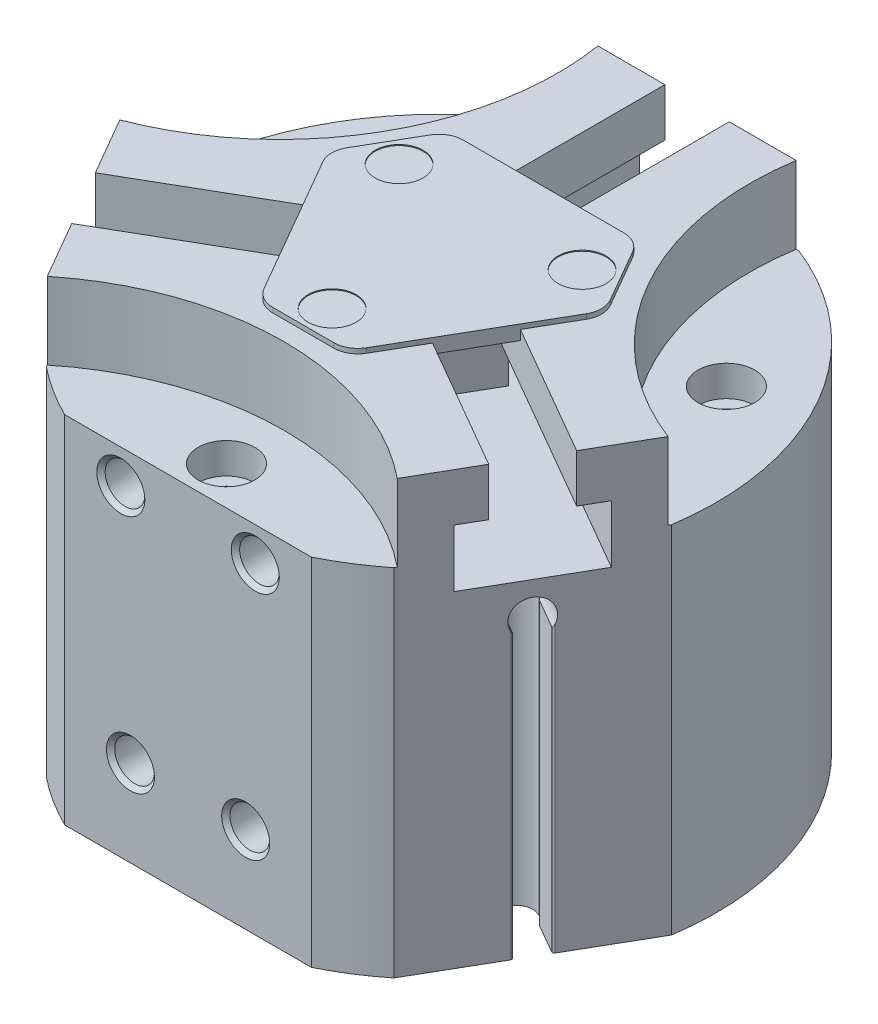
from build123d import *

# Parameters (mm, degrees)
BOSS_EXTRUDE1_DEPTH = 45
SKETCH2_W           = 68
SKETCH2_H           = 68
CUT_EXTRUDE1_DEPTH  = 8
CUT_EXTRUDE2_DEPTH  = 30.5
CUT_EXTRUDE3_DEPTH  = 30.5
CUT_EXTRUDE4_DEPTH  = 30.5
HOLE1_D             = 3
HOLE1_DEPTH         = 5
HOLE2_D             = 3
HOLE2_DEPTH         = 5
HOLE3_D             = 2.459
HOLE3_DEPTH         = 9
HOLE3_CSINK_D       = 3
HOLE3_CSINK_ANGLE   = 90
HOLE3_TIP           = 0.709852156
HOLE4_D             = 2.459
HOLE4_DEPTH         = 9
HOLE4_CSINK_D       = 3
HOLE4_CSINK_ANGLE   = 90
HOLE4_TIP           = 0.709852156
HOLE5_D             = 25
HOLE5_DEPTH         = 2
CUT_EXTRUDE5_DEPTH  = 16
CUT_EXTRUDE6_DEPTH  = 24.3
CUT_EXTRUDE7_DEPTH  = 16
CUT_EXTRUDE8_DEPTH  = 24.3
CUT_EXTRUDE9_DEPTH  = 16
CUT_EXTRUDE10_DEPTH = 24.3
BOSS_EXTRUDE2_DEPTH = 0.5
SKETCH33_R          = 2.5
CUT_EXTRUDE11_DEPTH = 0.1
SKETCH34_R          = 2.5
CUT_EXTRUDE12_DEPTH = 0.1
SKETCH35_R          = 2.5
CUT_EXTRUDE13_DEPTH = 0.1


with BuildPart() as part:
    # Sketch1 → Boss-Extrude1 (new body)
    with BuildSketch(Plane(origin=(0, 0, 0), x_dir=(1, 0, 0), z_dir=(0, 1, 0))):
        with BuildLine():
            Line((-28.674188524, -4.33484861), (-18.09118328, -22.66515139))
            ThreePointArc((-18.09118328, -22.66515139), (-15.55781991, -24.473541624), (-12.845232579, -26))
            Line((-12.845232579, -26), (12.845232579, -26))
            ThreePointArc((12.845232579, -26), (15.55781991, -24.473541624), (18.09118328, -22.66515139))
            Line((18.09118328, -22.66515139), (28.674188524, -4.33484861))
            ThreePointArc((28.674188524, -4.33484861), (25.11473671, 14.5), (10.583005244, 27))
            Line((10.583005244, 27), (-10.583005244, 27))
            ThreePointArc((-10.583005244, 27), (-25.11473671, 14.5), (-28.674188524, -4.33484861))
        make_face()
    extrude(amount=BOSS_EXTRUDE1_DEPTH)

    # Sketch2 → Cut-Extrude1 (cut)
    with BuildSketch(Plane(origin=(0, 45, 0), x_dir=(1, 0, 0), z_dir=(0, 1, 0))):
        Rectangle(SKETCH2_W, SKETCH2_H)
        with BuildLine():
            Line((-30, -30), (-24.819347292, -30))
            ThreePointArc((-24.819347292, -30), (0, -16), (24.819347292, -30))
            Line((24.819347292, -30), (30, -30))
            Line((30, -30), (30, -5.077501522))
            ThreePointArc((30, -5.077501522), (13.484446732, 8.664238198), (10.957753515, 30))
            Line((10.957753515, 30), (-10.957753515, 30))
            ThreePointArc((-10.957753515, 30), (-13.484446732, 8.664238198), (-30, -5.077501522))
            Line((-30, -5.077501522), (-30, -30))
        make_face(mode=Mode.SUBTRACT)
    extrude(amount=-CUT_EXTRUDE1_DEPTH, mode=Mode.SUBTRACT)

    # Sketch3 → Cut-Revolve1 (revolve, cut)
    with BuildSketch(Plane(origin=(0, 0, 0), x_dir=(0, 0, -1), z_dir=(1, 0, 0))):
        Polygon((-22, 37), (-19.05, 37), (-19.05, 33.8), (-20.35, 33.8), (-20.35, 8), (-20.379, 8), (-20.379, 0.379), (-20, 0), (-22, 0), align=None)
    revolve(axis=Axis((0, 0, 22), (0, 1, 0)), mode=Mode.SUBTRACT)

    # Sketch4 → Cut-Revolve2 (revolve, cut)
    with BuildSketch(Plane(origin=(19.05, 0, 0), x_dir=(0, 0, -1), z_dir=(1, 0, 0))):
        Polygon((11, 37), (13.95, 37), (13.95, 33.8), (12.65, 33.8), (12.65, 8), (12.621, 8), (12.621, 0.379), (13, 0), (11, 0), align=None)
    revolve(axis=Axis((19.05, 0, -11), (0, 1, 0)), mode=Mode.SUBTRACT)

    # Sketch5 → Cut-Revolve3 (revolve, cut)
    with BuildSketch(Plane(origin=(-19.05, 0, 0), x_dir=(0, 0, -1), z_dir=(1, 0, 0))):
        Polygon((11, 37), (13.95, 37), (13.95, 33.8), (12.65, 33.8), (12.65, 8), (12.621, 8), (12.621, 0.379), (13, 0), (11, 0), align=None)
    revolve(axis=Axis((-19.05, 0, -11), (0, 1, 0)), mode=Mode.SUBTRACT)

    # Sketch6 → Cut-Extrude2 (cut)
    with BuildSketch(Plane(origin=(0, 0, 0), x_dir=(1, 0, 0), z_dir=(0, 1, 0))):
        with BuildLine():
            Line((-1.9, 28), (-1.9, 27))
            Line((-1.9, 27), (-1.7, 27))
            ThreePointArc((-1.7, 27), (-1.558578644, 26.941421356), (-1.5, 26.8))
            Line((-1.5, 26.8), (-1.5, 23.3))
            ThreePointArc((-1.5, 23.3), (-1.551920858, 23.16556575), (-1.680725676, 23.100930915))
            Line((-1.680725676, 23.100930915), (-1.699955038, 23.099069085))
            ThreePointArc((-1.699955038, 23.099069085), (-1.834790164, 23.027476578), (-1.879833426, 22.881609849))
            Line((-1.879833426, 22.881609849), (-1.7923744, 21.93448864))
            ThreePointArc((-1.7923744, 21.93448864), (0, 20.3), (1.7923744, 21.93448864))
            Line((1.7923744, 21.93448864), (1.879833426, 22.881609849))
            ThreePointArc((1.879833426, 22.881609849), (1.834790164, 23.027476578), (1.699955038, 23.099069085))
            Line((1.699955038, 23.099069085), (1.680725676, 23.100930915))
            ThreePointArc((1.680725676, 23.100930915), (1.551920858, 23.16556575), (1.5, 23.3))
            Line((1.5, 23.3), (1.5, 26.8))
            ThreePointArc((1.5, 26.8), (1.558578644, 26.941421356), (1.7, 27))
            Line((1.7, 27), (1.9, 27))
            Line((1.9, 27), (1.9, 28))
            Line((1.9, 28), (-1.9, 28))
        make_face()
    extrude(amount=CUT_EXTRUDE2_DEPTH, mode=Mode.SUBTRACT)

    # Sketch7 → Cut-Extrude3 (cut)
    with BuildSketch(Plane(origin=(0, 0, 0), x_dir=(1, 0, 0), z_dir=(0, 1, 0))):
        with BuildLine():
            Line((-25.198711306, -12.354551733), (-23.298711306, -15.645448267))
            Line((-23.298711306, -15.645448267), (-22.432685902, -15.145448267))
            Line((-22.432685902, -15.145448267), (-22.532685902, -14.972243186))
            ThreePointArc((-22.532685902, -14.972243186), (-22.552665987, -14.820479377), (-22.459480821, -14.699038106))
            Line((-22.459480821, -14.699038106), (-19.428391908, -12.949038106))
            ThreePointArc((-19.428391908, -12.949038106), (-19.286008003, -12.926785762), (-19.165630186, -13.00601659))
            Line((-19.165630186, -13.00601659), (-19.154403112, -13.021738791))
            ThreePointArc((-19.154403112, -13.021738791), (-19.024984619, -13.102713181), (-18.876138696, -13.068788426))
            Line((-18.876138696, -13.068788426), (-18.099637181, -12.519486083))
            ThreePointArc((-18.099637181, -12.519486083), (-17.580315697, -10.15), (-19.892011581, -9.415002557))
            Line((-19.892011581, -9.415002557), (-20.755972122, -9.812821423))
            ThreePointArc((-20.755972122, -9.812821423), (-20.859774783, -9.924763397), (-20.85435815, -10.077330294))
            Line((-20.85435815, -10.077330294), (-20.846355862, -10.094914325))
            ThreePointArc((-20.846355862, -10.094914325), (-20.837928861, -10.238779987), (-20.928391908, -10.350961894))
            Line((-20.928391908, -10.350961894), (-23.959480821, -12.100961894))
            ThreePointArc((-23.959480821, -12.100961894), (-24.11124463, -12.120941979), (-24.232685902, -12.027756814))
            Line((-24.232685902, -12.027756814), (-24.332685902, -11.854551733))
            Line((-24.332685902, -11.854551733), (-25.198711306, -12.354551733))
        make_face()
    extrude(amount=CUT_EXTRUDE3_DEPTH, mode=Mode.SUBTRACT)

    # Sketch8 → Cut-Extrude4 (cut)
    with BuildSketch(Plane(origin=(0, 0, 0), x_dir=(1, 0, 0), z_dir=(0, 1, 0))):
        with BuildLine():
            Line((18.099637181, -12.519486083), (18.876138696, -13.068788426))
            ThreePointArc((18.876138696, -13.068788426), (19.024984619, -13.102713181), (19.154403112, -13.021738791))
            Line((19.154403112, -13.021738791), (19.165630186, -13.00601659))
            ThreePointArc((19.165630186, -13.00601659), (19.286008003, -12.926785762), (19.428391908, -12.949038106))
            Line((19.428391908, -12.949038106), (22.459480821, -14.699038106))
            ThreePointArc((22.459480821, -14.699038106), (22.552665987, -14.820479377), (22.532685902, -14.972243186))
            Line((22.532685902, -14.972243186), (22.432685902, -15.145448267))
            Line((22.432685902, -15.145448267), (23.298711306, -15.645448267))
            Line((23.298711306, -15.645448267), (25.198711306, -12.354551733))
            Line((25.198711306, -12.354551733), (24.332685902, -11.854551733))
            Line((24.332685902, -11.854551733), (24.232685902, -12.027756814))
            ThreePointArc((24.232685902, -12.027756814), (24.11124463, -12.120941979), (23.959480821, -12.100961894))
            Line((23.959480821, -12.100961894), (20.928391908, -10.350961894))
            ThreePointArc((20.928391908, -10.350961894), (20.837928861, -10.238779987), (20.846355862, -10.094914325))
            Line((20.846355862, -10.094914325), (20.85435815, -10.077330294))
            ThreePointArc((20.85435815, -10.077330294), (20.859774783, -9.924763397), (20.755972122, -9.812821423))
            Line((20.755972122, -9.812821423), (19.892011581, -9.415002557))
            ThreePointArc((19.892011581, -9.415002557), (17.580315697, -10.15), (18.099637181, -12.519486083))
        make_face()
    extrude(amount=CUT_EXTRUDE4_DEPTH, mode=Mode.SUBTRACT)

    # Sketch9 → Cut-Revolve4 (revolve, cut)
    with BuildSketch(Plane(origin=(0, 30.5, 0), x_dir=(1, 0, 0), z_dir=(0, 1, 0))):
        with BuildLine():
            Line((-1.7923744, 21.93448864), (-1.9, 23.1))
            Line((-1.9, 23.1), (-1.9, 27))
            Line((-1.9, 27), (0, 27))
            Line((0, 27), (0, 20.3))
            ThreePointArc((0, 20.3), (-1.212864286, 20.76997736), (-1.7923744, 21.93448864))
        make_face()
    revolve(axis=Axis((0, 30.5, -27), (0, 0, 1)), mode=Mode.SUBTRACT)

    # Sketch10 → Cut-Revolve5 (revolve, cut)
    with BuildSketch(Plane(origin=(0, 30.5, 0), x_dir=(1, 0, 0), z_dir=(0, 1, 0))):
        with BuildLine():
            Line((-18.099637181, -12.519486083), (-19.055186827, -13.195448267))
            Line((-19.055186827, -13.195448267), (-22.432685902, -15.145448267))
            Line((-22.432685902, -15.145448267), (-23.382685902, -13.5))
            Line((-23.382685902, -13.5), (-17.580315697, -10.15))
            ThreePointArc((-17.580315697, -10.15), (-17.380895886, -11.435359963), (-18.099637181, -12.519486083))
        make_face()
    revolve(axis=Axis((-23.382685902, 30.5, 13.5), (0.8660254037844486, 0, -0.49999999999998296)), mode=Mode.SUBTRACT)

    # Sketch11 → Cut-Revolve6 (revolve, cut)
    with BuildSketch(Plane(origin=(0, 30.5, 0), x_dir=(1, 0, 0), z_dir=(0, 1, 0))):
        with BuildLine():
            Line((19.892011581, -9.415002557), (20.955186827, -9.904551733))
            Line((20.955186827, -9.904551733), (24.332685902, -11.854551733))
            Line((24.332685902, -11.854551733), (23.382685902, -13.5))
            Line((23.382685902, -13.5), (17.580315697, -10.15))
            ThreePointArc((17.580315697, -10.15), (18.593760172, -9.334617397), (19.892011581, -9.415002557))
        make_face()
    revolve(axis=Axis((23.382685902, 30.5, 13.5), (-0.8660254037844486, 0, -0.49999999999998296)), mode=Mode.SUBTRACT)

    # Hole1
    with Locations(Plane(origin=(0, 0, 0), x_dir=(-1, 0, 0), z_dir=(0, -1, 0))):
        with Locations((-22.5, 0)):
            Hole(HOLE1_D / 2, depth=HOLE1_DEPTH)

    # Hole2
    with Locations(Plane(origin=(0, 0, 0), x_dir=(-1, 0, 0), z_dir=(0, -1, 0))):
        with Locations((22.5, 0)):
            Hole(HOLE2_D / 2, depth=HOLE2_DEPTH)

    # Hole3
    with Locations(Plane(origin=(0, 0, 0), x_dir=(-1, 0, 0), z_dir=(0, -1, 0))):
        with Locations((-7.5, -18.5)):
            CounterSinkHole(HOLE3_D / 2, HOLE3_CSINK_D / 2, depth=HOLE3_DEPTH, counter_sink_angle=HOLE3_CSINK_ANGLE)
            with Locations((0, 0, -(HOLE3_DEPTH + HOLE3_TIP / 2))):  # 120° drill point
                Cone(0, HOLE3_D / 2, HOLE3_TIP, mode=Mode.SUBTRACT)

    # Hole4
    with Locations(Plane(origin=(0, 0, 0), x_dir=(-1, 0, 0), z_dir=(0, -1, 0))):
        with Locations((7.5, -18.5)):
            CounterSinkHole(HOLE4_D / 2, HOLE4_CSINK_D / 2, depth=HOLE4_DEPTH, counter_sink_angle=HOLE4_CSINK_ANGLE)
            with Locations((0, 0, -(HOLE4_DEPTH + HOLE4_TIP / 2))):  # 120° drill point
                Cone(0, HOLE4_D / 2, HOLE4_TIP, mode=Mode.SUBTRACT)

    # Sketch20 → Cut-Revolve7 (revolve, cut)
    with BuildSketch(Plane(origin=(-6, 0, 0), x_dir=(0, 0, -1), z_dir=(1, 0, 0))):
        Polygon((-26, 9), (-26, 11.5), (-25.567, 11.067), (-19.5, 11.067), (-18.306616994, 9), align=None)
    revolve(axis=Axis((-6, 9, 18.306616994), (0, 0, 1)), mode=Mode.SUBTRACT)

    # Sketch21 → Cut-Revolve8 (revolve, cut)
    with BuildSketch(Plane(origin=(6, 0, 0), x_dir=(0, 0, -1), z_dir=(1, 0, 0))):
        Polygon((-26, 9), (-26, 11.5), (-25.567, 11.067), (-19.5, 11.067), (-18.306616994, 9), align=None)
    revolve(axis=Axis((6, 9, 18.306616994), (0, 0, 1)), mode=Mode.SUBTRACT)

    # Sketch22 → Cut-Revolve9 (revolve, cut)
    with BuildSketch(Plane(origin=(7, 0, 0), x_dir=(0, 0, -1), z_dir=(1, 0, 0))):
        Polygon((-26, 33.5), (-26, 36), (-25.567, 35.567), (-19.5, 35.567), (-18.306616994, 33.5), align=None)
    revolve(axis=Axis((7, 33.5, 18.306616994), (0, 0, 1)), mode=Mode.SUBTRACT)

    # Sketch23 → Cut-Revolve10 (revolve, cut)
    with BuildSketch(Plane(origin=(-7, 0, 0), x_dir=(0, 0, -1), z_dir=(1, 0, 0))):
        Polygon((-26, 33.5), (-26, 36), (-25.567, 35.567), (-19.5, 35.567), (-18.306616994, 33.5), align=None)
    revolve(axis=Axis((-7, 33.5, 18.306616994), (0, 0, 1)), mode=Mode.SUBTRACT)

    # Hole5
    with Locations(Plane(origin=(0, 0, 0), x_dir=(-1, 0, 0), z_dir=(0, -1, 0))):
        with Locations((0, 0)):
            Hole(HOLE5_D / 2, depth=HOLE5_DEPTH)

    # Sketch26 → Cut-Extrude5 (cut)
    with BuildSketch(Plane.XY.offset(-27)):
        Polygon((-6, 34), (6, 34), (6, 40), (3.35, 40), (3.35, 46), (-3.35, 46), (-3.35, 40), (-6, 40), align=None)
    extrude(amount=CUT_EXTRUDE5_DEPTH, mode=Mode.SUBTRACT)

    # Sketch27 → Cut-Extrude6 (cut)
    with BuildSketch(Plane.XY.offset(-27)):
        Polygon((-6, 34), (6, 34), (6, 40), (3.35, 40), (3.35, 44), (-3.35, 44), (-3.35, 40), (-6, 40), align=None)
    extrude(amount=CUT_EXTRUDE6_DEPTH, mode=Mode.SUBTRACT)

    # Sketch28 → Cut-Extrude7 (cut)
    with BuildSketch(Plane(origin=(23.382685902, 0, 13.5), x_dir=(0.4999999999999995, 0, -0.866025403784439), z_dir=(0.8660254037844389, 0, 0.49999999999999944))):
        Polygon((-6, 34), (6, 34), (6, 40), (3.35, 40), (3.35, 46), (-3.35, 46), (-3.35, 40), (-6, 40), align=None)
    extrude(amount=-CUT_EXTRUDE7_DEPTH, mode=Mode.SUBTRACT)

    # Sketch29 → Cut-Extrude8 (cut)
    with BuildSketch(Plane(origin=(23.382685902, 0, 13.5), x_dir=(0.4999999999999995, 0, -0.866025403784439), z_dir=(0.8660254037844389, 0, 0.49999999999999944))):
        Polygon((-6, 34), (6, 34), (6, 40), (3.35, 40), (3.35, 44), (-3.35, 44), (-3.35, 40), (-6, 40), align=None)
    extrude(amount=-CUT_EXTRUDE8_DEPTH, mode=Mode.SUBTRACT)

    # Sketch30 → Cut-Extrude9 (cut)
    with BuildSketch(Plane(origin=(-23.382685902, 0, 13.5), x_dir=(-0.4999999999999995, 0, -0.866025403784439), z_dir=(0.8660254037844389, 0, -0.49999999999999944))):
        Polygon((-6, 34), (6, 34), (6, 40), (3.35, 40), (3.35, 46), (-3.35, 46), (-3.35, 40), (-6, 40), align=None)
    extrude(amount=CUT_EXTRUDE9_DEPTH, mode=Mode.SUBTRACT)

    # Sketch31 → Cut-Extrude10 (cut)
    with BuildSketch(Plane(origin=(-23.382685902, 0, 13.5), x_dir=(-0.4999999999999995, 0, -0.866025403784439), z_dir=(0.8660254037844389, 0, -0.49999999999999944))):
        Polygon((-6, 34), (6, 34), (6, 40), (3.35, 40), (3.35, 44), (-3.35, 44), (-3.35, 40), (-6, 40), align=None)
    extrude(amount=CUT_EXTRUDE10_DEPTH, mode=Mode.SUBTRACT)

    # Sketch32 → Boss-Extrude2 (add)
    with BuildSketch(Plane(origin=(0, 45, 0), x_dir=(1, 0, 0), z_dir=(0, 1, 0))):
        with BuildLine():
            Line((-13.712068893, 1.75), (-5.34048999, -12.75))
            ThreePointArc((-5.34048999, -12.75), (-4.425426481, -13.665063509), (-3.175426481, -14))
            Line((-3.175426481, -14), (3.175426481, -14))
            ThreePointArc((3.175426481, -14), (4.425426481, -13.665063509), (5.34048999, -12.75))
            Line((5.34048999, -12.75), (13.712068893, 1.75))
            ThreePointArc((13.712068893, 1.75), (14.047005384, 3), (13.712068893, 4.25))
            Line((13.712068893, 4.25), (10.536642413, 9.75))
            ThreePointArc((10.536642413, 9.75), (9.621578903, 10.665063509), (8.371578903, 11))
            Line((8.371578903, 11), (-8.371578903, 11))
            ThreePointArc((-8.371578903, 11), (-9.621578903, 10.665063509), (-10.536642413, 9.75))
            Line((-10.536642413, 9.75), (-13.712068893, 4.25))
            ThreePointArc((-13.712068893, 4.25), (-14.047005384, 3), (-13.712068893, 1.75))
        make_face()
    extrude(amount=BOSS_EXTRUDE2_DEPTH)

    # Sketch33 → Cut-Extrude11 (cut)
    with BuildSketch(Plane(origin=(0, 45.5, 0), x_dir=(1, 0, 0), z_dir=(0, 1, 0))):
        with Locations((0, -11)):
            Circle(SKETCH33_R)
    extrude(amount=-CUT_EXTRUDE11_DEPTH, mode=Mode.SUBTRACT)

    # Sketch34 → Cut-Extrude12 (cut)
    with BuildSketch(Plane(origin=(0, 45.5, 0), x_dir=(1, 0, 0), z_dir=(0, 1, 0))):
        with Locations((9.526279442, 5.5)):
            Circle(SKETCH34_R)
    extrude(amount=-CUT_EXTRUDE12_DEPTH, mode=Mode.SUBTRACT)

    # Sketch35 → Cut-Extrude13 (cut)
    with BuildSketch(Plane(origin=(0, 45.5, 0), x_dir=(1, 0, 0), z_dir=(0, 1, 0))):
        with Locations((-9.526279442, 5.5)):
            Circle(SKETCH35_R)
    extrude(amount=-CUT_EXTRUDE13_DEPTH, mode=Mode.SUBTRACT)


solid = part.part
